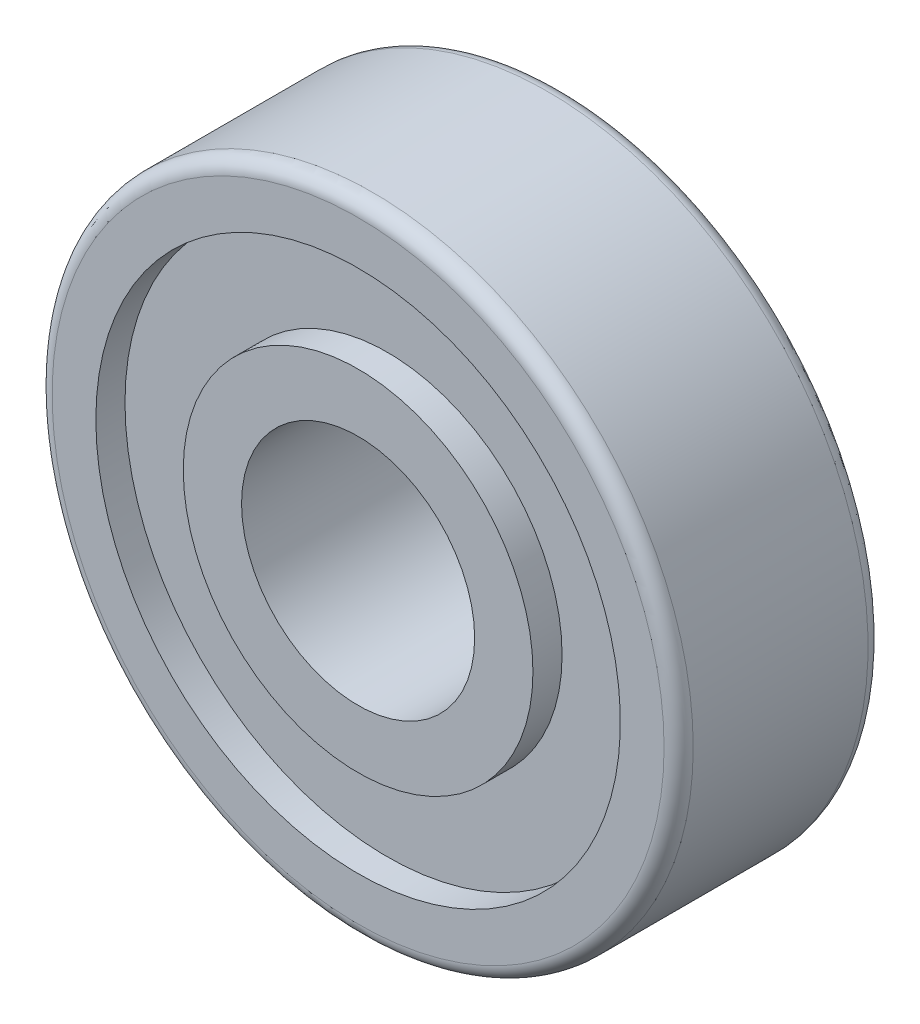
from build123d import *

# Parameters (mm, degrees)
FILLET1_R = 0.5


with BuildPart() as part:
    # Sketch1 → Revolve1 (revolve)
    with BuildSketch(Plane.XZ):
        Polygon((6, -3.5), (6, -2.5), (9, -2.5), (9, -3.5), (11, -3.5), (11, 3.5), (9, 3.5), (9, 2.5), (6, 2.5), (6, 3.5), (4, 3.5), (4, -3.5), align=None)
    revolve(axis=Axis((0, 0, 3.5), (0, 0, -1)))

    # Fillet1
    fillet1_edges = [part.edges().sort_by_distance(p)[0] for p in [
        (-11, 0, 3.5),
        (-11, 0, -3.5),
    ]]
    fillet(fillet1_edges, radius=FILLET1_R)


solid = part.part
